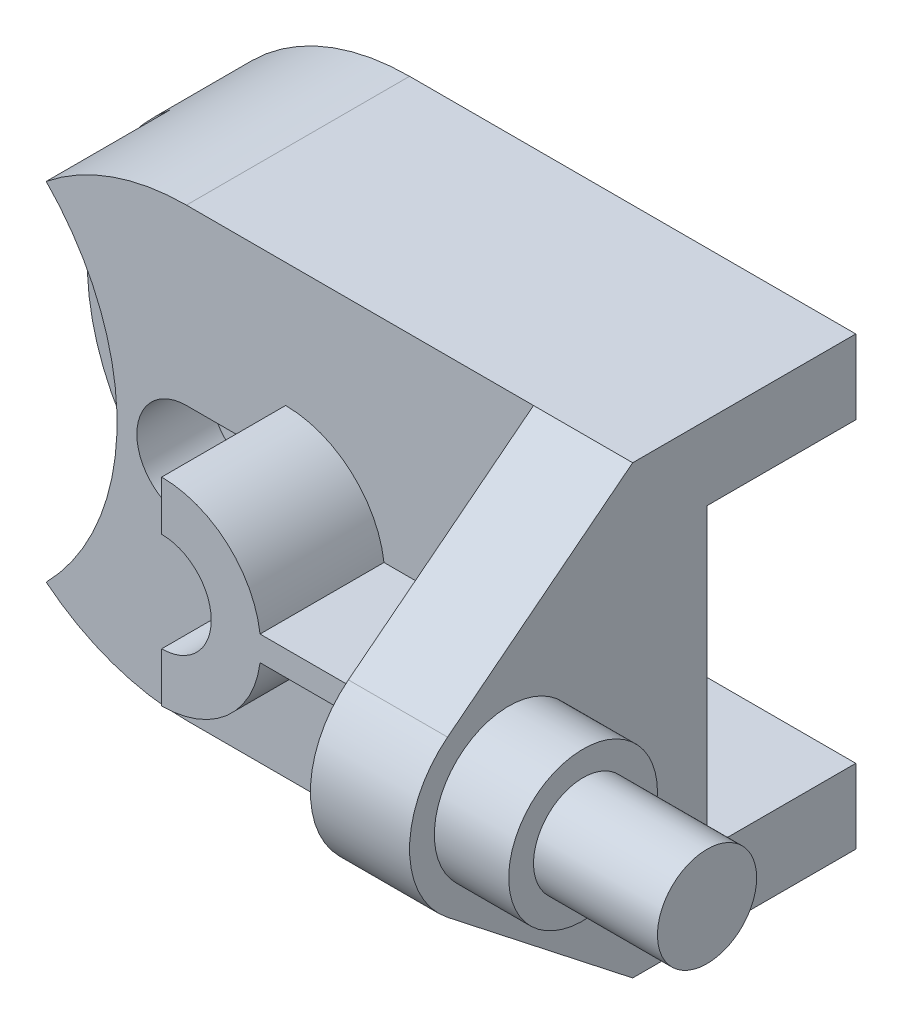
from build123d import *

# Parameters (mm, degrees)
SKETCH1_W           = 175
SKETCH1_H           = 90
BOSS_EXTRUDE1_DEPTH = 90
CUT_EXTRUDE1_DEPTH  = 90
SKETCH3_W           = 40
SKETCH3_H           = 30
CUT_EXTRUDE2_DEPTH  = 90
SKETCH4_W           = 25
SKETCH4_H           = 5
CUT_EXTRUDE3_DEPTH  = 90
CUT_EXTRUDE4_DEPTH  = 70
CUT_EXTRUDE5_DEPTH  = 308
CUT_EXTRUDE6_DEPTH  = 30
CUT_EXTRUDE7_DEPTH  = 25
CUT_EXTRUDE8_DEPTH  = 15
SKETCH10_W          = 45
SKETCH10_H          = 90
CUT_EXTRUDE9_DEPTH  = 154
BOSS_EXTRUDE2_DEPTH = 25
CUT_EXTRUDE10_DEPTH = 15
SKETCH13_W          = 30.156865167
SKETCH13_H          = 5
BOSS_EXTRUDE3_DEPTH = 25


with BuildPart() as part:
    # Sketch1 → Boss-Extrude1 (new body)
    with BuildSketch(Plane.XY):
        with Locations((87.5, 45)):
            Rectangle(SKETCH1_W, SKETCH1_H)
    extrude(amount=BOSS_EXTRUDE1_DEPTH)

    # Sketch2 → Cut-Extrude1 (cut)
    with BuildSketch(Plane.XY.offset(90)):
        with BuildLine():
            Line((45, 90), (0, 90))
            Line((0, 90), (0, 45))
            ThreePointArc((0, 45), (13.180194847, 76.819805153), (45, 90))
        make_face()
        with BuildLine():
            ThreePointArc((45, 0), (13.180194847, 13.180194847), (0, 45))
            Line((0, 45), (0, 0))
            Line((0, 0), (45, 0))
        make_face()
    extrude(amount=-CUT_EXTRUDE1_DEPTH, mode=Mode.SUBTRACT)

    # Sketch3 → Cut-Extrude2 (cut)
    with BuildSketch(Plane.XY.offset(90)):
        with Locations((155, 75)):
            Rectangle(SKETCH3_W, SKETCH3_H)
        with Locations((155, 15)):
            Rectangle(SKETCH3_W, SKETCH3_H)
    extrude(amount=-CUT_EXTRUDE2_DEPTH, mode=Mode.SUBTRACT)

    # Sketch4 → Cut-Extrude3 (cut)
    with BuildSketch(Plane.XY.offset(90)):
        with Locations((162.5, 57.5)):
            Rectangle(SKETCH4_W, SKETCH4_H)
        with Locations((162.5, 32.5)):
            Rectangle(SKETCH4_W, SKETCH4_H)
    extrude(amount=-CUT_EXTRUDE3_DEPTH, mode=Mode.SUBTRACT)

    # Sketch5 → Cut-Extrude4 (cut)
    with BuildSketch(Plane.XY.offset(90)):
        with BuildLine():
            ThreePointArc((16.715728753, 10), (31.00858661, 45), (16.715728753, 80))
            ThreePointArc((16.715728753, 80), (0, 45), (16.715728753, 10))
        make_face()
    extrude(amount=-CUT_EXTRUDE4_DEPTH, mode=Mode.SUBTRACT)

    # Sketch6 → Cut-Extrude5 (cut)
    with BuildSketch(Plane(origin=(0, 0, 0), x_dir=(0, 0, -1), z_dir=(1, 0, 0))):
        with BuildLine():
            Line((-82.336131476, 60.742295265), (-45, 90))
            Line((-45, 90), (-90, 90))
            Line((-90, 90), (-90, 45))
            ThreePointArc((-90, 45), (-87.982249992, 53.75435236), (-82.336131476, 60.742295265))
        make_face()
        with BuildLine():
            ThreePointArc((-82.336131476, 29.257704735), (-87.982249992, 36.24564764), (-90, 45))
            Line((-90, 45), (-90, 0))
            Line((-90, 0), (-45, 0))
            Line((-45, 0), (-82.336131476, 29.257704735))
        make_face()
    extrude(amount=CUT_EXTRUDE5_DEPTH, mode=Mode.SUBTRACT)

    # Sketch7 → Cut-Extrude6 (cut)
    with BuildSketch(Plane(origin=(0, 0, 0), x_dir=(-1, 0, 0), z_dir=(0, 0, -1))):
        with BuildLine():
            Line((-135, 75), (-45, 75))
            ThreePointArc((-45, 75), (-15, 45), (-45, 15))
            Line((-45, 15), (-135, 15))
            Line((-135, 15), (-135, 75))
        make_face()
    extrude(amount=-CUT_EXTRUDE6_DEPTH, mode=Mode.SUBTRACT)

    # Sketch8 → Cut-Extrude7 (cut)
    with BuildSketch(Plane(origin=(175, 0, 0), x_dir=(0, 0, -1), z_dir=(1, 0, 0))):
        with BuildLine():
            Line((-70, 55), (-87.320508076, 55))
            ThreePointArc((-87.320508076, 55), (-90, 45), (-87.320508076, 35))
            Line((-87.320508076, 35), (-70, 35))
            ThreePointArc((-70, 35), (-80, 45), (-70, 55))
        make_face()
        with BuildLine():
            Line((0, 55), (-70, 55))
            ThreePointArc((-70, 55), (-62.928932188, 52.071067812), (-60, 45))
            ThreePointArc((-60, 45), (-62.928932188, 37.928932188), (-70, 35))
            Line((-70, 35), (0, 35))
            Line((0, 35), (0, 55))
        make_face()
    extrude(amount=-CUT_EXTRUDE7_DEPTH, mode=Mode.SUBTRACT)

    # Sketch9 → Cut-Extrude8 (cut)
    with BuildSketch(Plane(origin=(150, 0, 0), x_dir=(0, 0, -1), z_dir=(1, 0, 0))):
        with BuildLine():
            Line((-70, 60), (-83.228756555, 60))
            ThreePointArc((-83.228756555, 60), (-90, 45), (-83.228756555, 30))
            Line((-83.228756555, 30), (-70, 30))
            ThreePointArc((-70, 30), (-85, 45), (-70, 60))
        make_face()
        with BuildLine():
            Line((0, 60), (-70, 60))
            ThreePointArc((-70, 60), (-59.393398282, 55.606601718), (-55, 45))
            ThreePointArc((-55, 45), (-59.393398282, 34.393398282), (-70, 30))
            Line((-70, 30), (0, 30))
            Line((0, 30), (0, 60))
        make_face()
    extrude(amount=-CUT_EXTRUDE8_DEPTH, mode=Mode.SUBTRACT)

    # Sketch10 → Cut-Extrude9 (cut)
    with BuildSketch(Plane(origin=(115, 0, 0), x_dir=(0, 0, -1), z_dir=(1, 0, 0))):
        with Locations((-67.5, 45)):
            Rectangle(SKETCH10_W, SKETCH10_H)
    extrude(amount=-CUT_EXTRUDE9_DEPTH, mode=Mode.SUBTRACT)

    # Sketch11 → Boss-Extrude2 (add)
    with BuildSketch(Plane.XY.offset(45)):
        with BuildLine():
            Line((65, 55), (65, 65))
            ThreePointArc((65, 65), (85, 45), (65, 25))
            Line((65, 25), (65, 35))
            ThreePointArc((65, 35), (75, 45), (65, 55))
        make_face()
    extrude(amount=BOSS_EXTRUDE2_DEPTH)

    # Sketch12 → Cut-Extrude10 (cut)
    with BuildSketch(Plane.XY.offset(45)):
        with BuildLine():
            Line((65, 35), (45, 35))
            ThreePointArc((45, 35), (35, 45), (45, 55))
            Line((45, 55), (65, 55))
            ThreePointArc((65, 55), (75, 45), (65, 35))
        make_face()
    extrude(amount=-CUT_EXTRUDE10_DEPTH, mode=Mode.SUBTRACT)

    # Sketch13 → Boss-Extrude3 (add)
    with BuildSketch(Plane.XY.offset(45)):
        with Locations((99.921567417, 45)):
            Rectangle(SKETCH13_W, SKETCH13_H)
    extrude(amount=BOSS_EXTRUDE3_DEPTH)


solid = part.part
